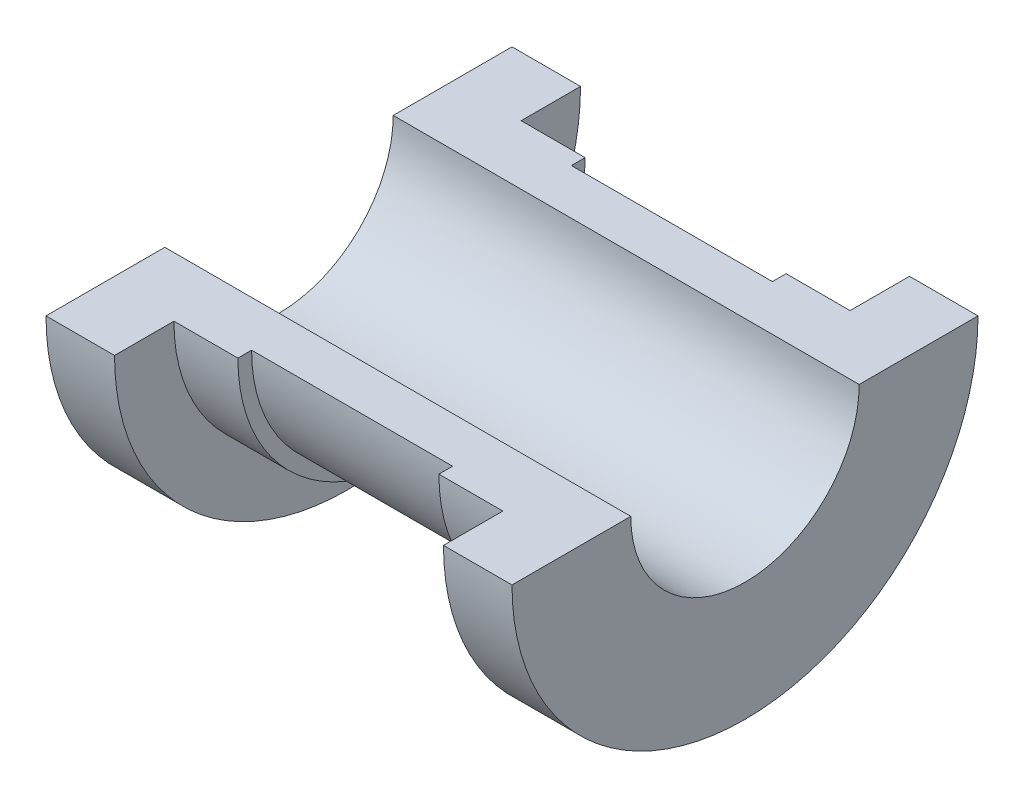
from build123d import *

# Parameters (mm, degrees)
REVOLVE3_ANGLE      = 180
CUT_EXTRUDE1_DEPTH  = 52
SKETCH11_R          = 3
BOSS_EXTRUDE2_DEPTH = 6


with BuildPart() as part:
    # Sketch2 → Revolve3 (revolve)
    with BuildSketch(Plane(origin=(0, 0, 0), x_dir=(1, 0, 0), z_dir=(0, 1, 0))):
        Polygon((25.5, 0), (-25.5, 0), (-25.5, 25.5), (-18, 25.5), (-18, 19), (-11, 19), (-11, 17.5), (11, 17.5), (11, 19), (18, 19), (18, 25.5), (25.5, 25.5), align=None)
    revolve(axis=Axis((25.5, 0, 0), (-1, 0, 0)), revolution_arc=REVOLVE3_ANGLE)

    # Sketch3 → Cut-Extrude1 (cut, through all)
    with BuildSketch(Plane.ZY.offset(25.5)):
        with BuildLine():
            Line((12.5, 0), (-12.5, 0))
            ThreePointArc((-12.5, 0), (0, -12.5), (12.5, 0))
        make_face()
    extrude(amount=-CUT_EXTRUDE1_DEPTH, mode=Mode.SUBTRACT)


with BuildPart() as body_2:
    # Sketch11 → Boss-Extrude2 (new body)
    with BuildSketch(Plane(origin=(0, -17.5, 0), x_dir=(-1, 0, 0), z_dir=(0, -1, 0))):
        with Locations(Location((0, 0, 0), (0, 0, 90))):  # turned: the seam where the file's is
            Circle(SKETCH11_R)
    extrude(amount=BOSS_EXTRUDE2_DEPTH)


solid = Compound([part.part, body_2.part])
